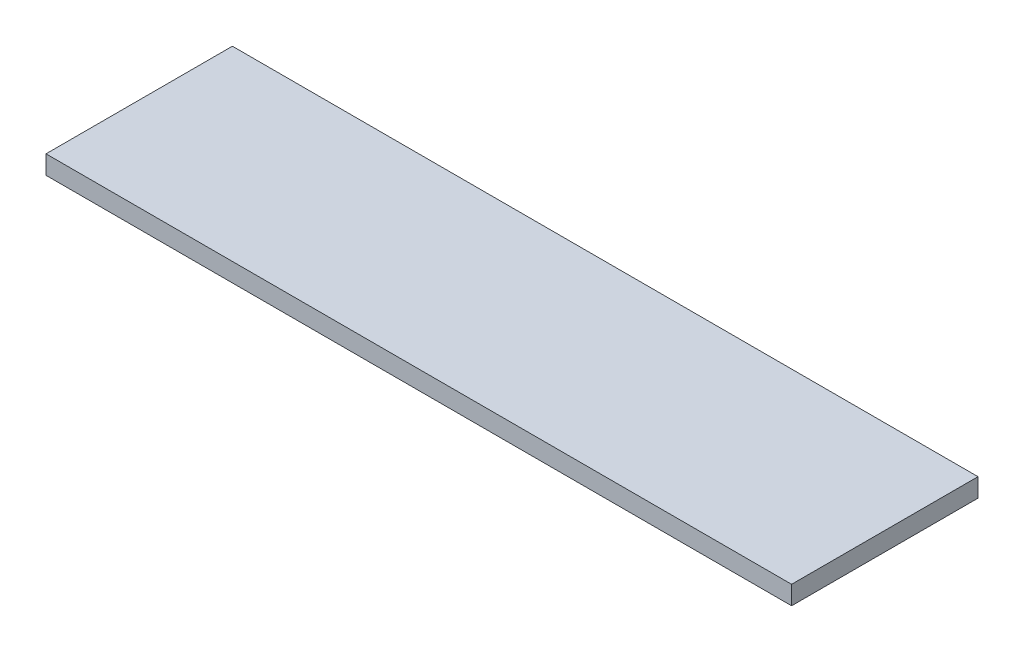
from build123d import *

# Parameters (mm, degrees)
ESQUISSE1_W      = 200
ESQUISSE1_H      = 50
EXTRUSION1_DEPTH = 5


with BuildPart() as part:
    # Esquisse1 → Extrusion1 (new body)
    with BuildSketch(Plane(origin=(0, 0, 0), x_dir=(1, 0, 0), z_dir=(0, 1, 0))):
        with Locations((100, 25)):
            Rectangle(ESQUISSE1_W, ESQUISSE1_H)
    extrude(amount=EXTRUSION1_DEPTH)


solid = part.part
